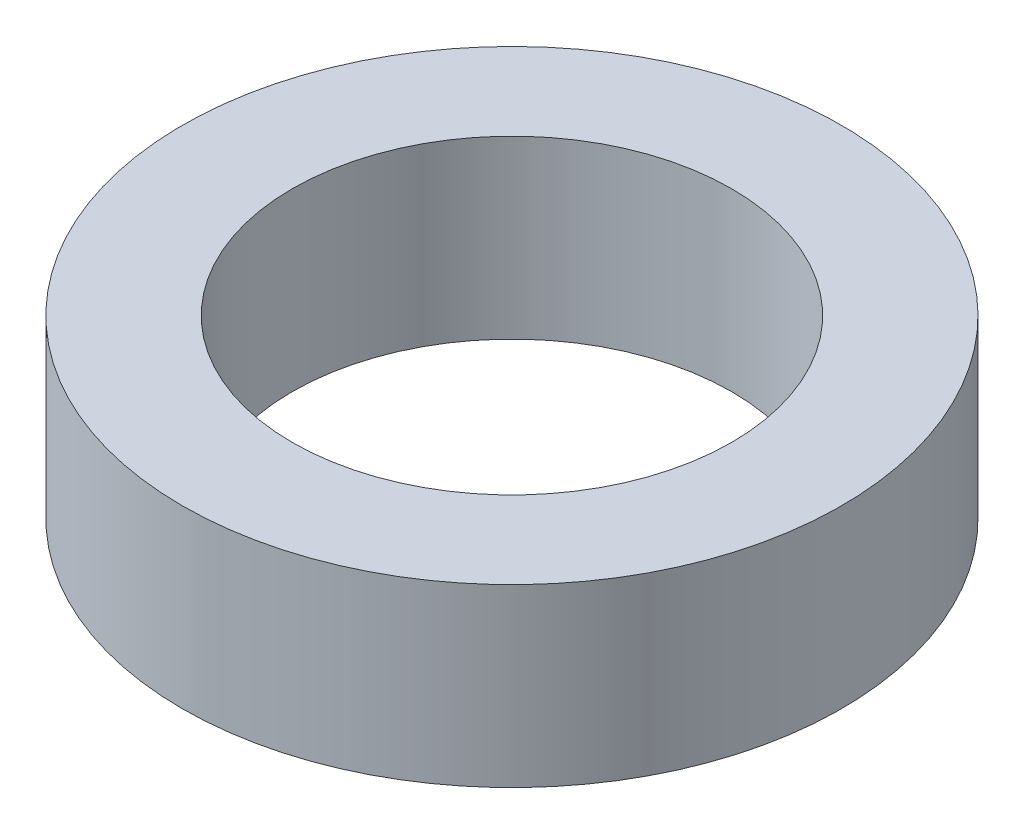
from build123d import *

# Parameters (mm, degrees)
SKETCH1_R           = 4.7625
SKETCH1_R_2         = 3.175
BOSS_EXTRUDE1_DEPTH = 2.54


with BuildPart() as part:
    # Sketch1 → Boss-Extrude1 (new body)
    with BuildSketch(Plane(origin=(0, 0, 0), x_dir=(1, 0, 0), z_dir=(0, 1, 0))):
        Circle(SKETCH1_R)
        Circle(SKETCH1_R_2, mode=Mode.SUBTRACT)
    extrude(amount=BOSS_EXTRUDE1_DEPTH)


solid = part.part
